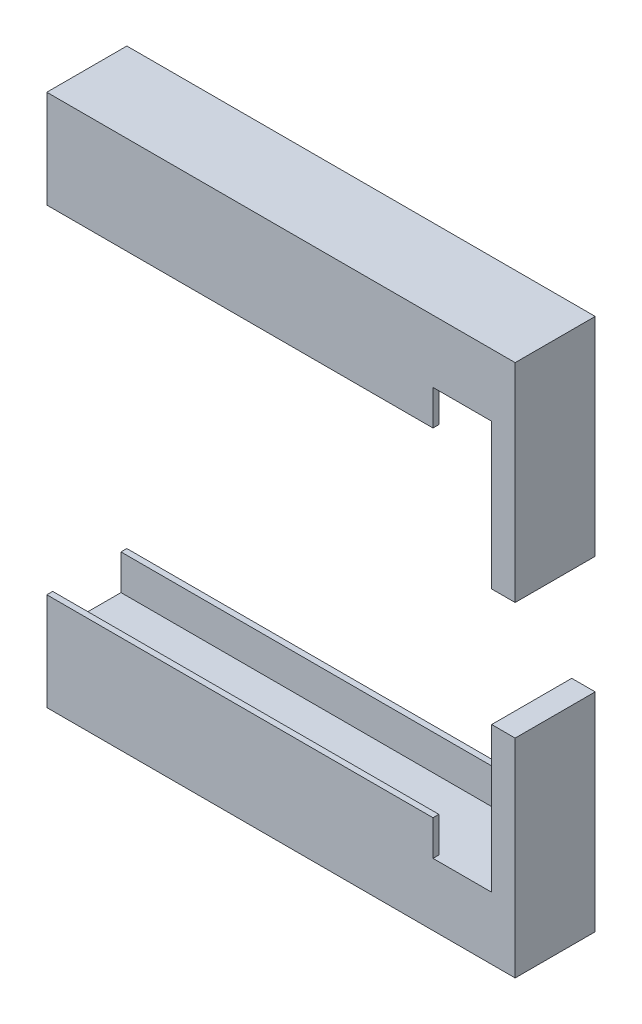
from build123d import *

# Parameters (mm, degrees)
SKETCH1_W                 = 6.82
SKETCH1_H                 = 45.402
BOSS_EXTRUDE1_DEPTH       = 39.9
CUT_EXTRUDE1_DEPTH        = 35.9
CUT_EXTRUDE2_DEPTH        = 2
CUT_EXTRUDE4_DEPTH        = 7.82
F_3_48_TAPPED_HOLE1_D     = 1.9939
F_3_48_TAPPED_HOLE1_DEPTH = 7.671
F_3_48_TAPPED_HOLE1_TIP   = 0.599027994
CUT_EXTRUDE3_REACH        = 41.9
SKETCH6_W                 = 6.82
SKETCH6_H                 = 10


with BuildPart() as part:
    # Sketch1 → Boss-Extrude1 (new body)
    with BuildSketch(Plane(origin=(0, 0, 0), x_dir=(0, 0, -1), z_dir=(1, 0, 0))):
        with Locations((3.41, 22.701)):
            Rectangle(SKETCH1_W, SKETCH1_H)
    extrude(amount=BOSS_EXTRUDE1_DEPTH)

    # Sketch2 → Cut-Extrude1 (cut)
    with BuildSketch(Plane.ZY):
        Polygon((-6.32, 5.326), (-0.5, 5.326), (-0.5, 8.326), (0, 8.326), (0, 37.076), (-0.5, 37.076), (-0.5, 40.076), (-6.32, 40.076), (-6.32, 37.076), (-6.82, 37.076), (-6.82, 22.701), (-6.82, 8.326), (-6.32, 8.326), align=None)
    extrude(amount=-CUT_EXTRUDE1_DEPTH, mode=Mode.SUBTRACT)

    # Sketch3 → Cut-Extrude2 (cut)
    with BuildSketch(Plane.ZY.offset(-35.9)):
        Polygon((-6.32, 40.076), (-6.32, 37.076), (-6.82, 37.076), (-6.82, 8.326), (-6.32, 8.326), (-6.32, 5.326), (-0.5, 5.326), (-0.5, 8.326), (0, 8.326), (0, 37.076), (-0.5, 37.076), (-0.5, 40.076), align=None)
    extrude(amount=-CUT_EXTRUDE2_DEPTH, mode=Mode.SUBTRACT)

    # Sketch7 → Cut-Extrude4 (cut, through all)
    with BuildSketch(Plane.XY):
        Polygon((37.9, 37.076), (37.9, 8.326), (37.9, 5.326), (32.9, 5.326), (32.9, 40.076), (37.9, 40.076), align=None)
    extrude(amount=-CUT_EXTRUDE4_DEPTH, mode=Mode.SUBTRACT)

    # #3-48 Tapped Hole1
    with Locations(Plane.ZY):
        with Locations((-3.41, 1.5), (-3.41, 43.902)):
            Hole(F_3_48_TAPPED_HOLE1_D / 2, depth=F_3_48_TAPPED_HOLE1_DEPTH)
            with Locations((0, 0, -(F_3_48_TAPPED_HOLE1_DEPTH + F_3_48_TAPPED_HOLE1_TIP / 2))):  # 118° drill point
                Cone(0, F_3_48_TAPPED_HOLE1_D / 2, F_3_48_TAPPED_HOLE1_TIP, mode=Mode.SUBTRACT)

    # Sketch6 → Cut-Extrude3 (cut, up to next)
    with BuildSketch(Plane(origin=(39.9, 0, 0), x_dir=(0, 0, -1), z_dir=(1, 0, 0)), mode=Mode.PRIVATE) as cut_extrude3_sk1:
        with Locations((3.41, 22.701)):
            Rectangle(SKETCH6_W, SKETCH6_H)
    cut_extrude3_tool1 = extrude(cut_extrude3_sk1.sketch, amount=-CUT_EXTRUDE3_REACH, mode=Mode.PRIVATE) & part.part
    add(cut_extrude3_tool1.solids().sort_by_distance((39.9, 22.701, -3.41))[0], mode=Mode.SUBTRACT)


solid = part.part
